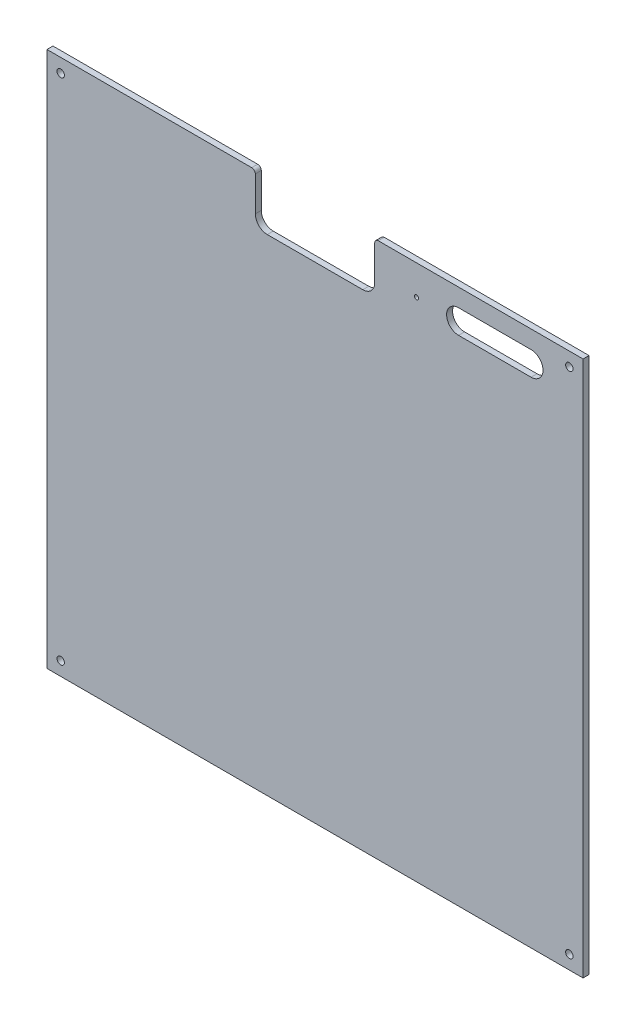
from build123d import *

# Parameters (mm, degrees)
SCHIZZO1_R                   = 3.1
SCHIZZO1_R_2                 = 1.75
ESTRUSIONE_ESTRUSIONE1_DEPTH = 5


with BuildPart() as part:
    # Schizzo1 → Estrusione-Estrusione1 (new body)
    with BuildSketch(Plane.XY):
        with BuildLine():
            Line((0, 0), (0, 449))
            Line((0, 449), (171.5, 449))
            ThreePointArc((171.5, 449), (173.621320344, 448.121320344), (174.5, 446))
            Line((174.5, 446), (174.5, 417))
            ThreePointArc((174.5, 417), (177.428932188, 409.928932188), (184.5, 407))
            Line((184.5, 407), (264.5, 407))
            ThreePointArc((264.5, 407), (271.571067812, 409.928932188), (274.5, 417))
            Line((274.5, 417), (274.5, 446))
            ThreePointArc((274.5, 446), (275.378679656, 448.121320344), (277.5, 449))
            Line((277.5, 449), (449, 449))
            Line((449, 449), (449, 0))
            Line((449, 0), (0, 0))
        make_face()
        with Locations((11.5, 11.5)):
            Circle(SCHIZZO1_R, mode=Mode.SUBTRACT)
        with Locations((437.5, 11.5)):
            Circle(SCHIZZO1_R, mode=Mode.SUBTRACT)
        with Locations((437.5, 437.5)):
            Circle(SCHIZZO1_R, mode=Mode.SUBTRACT)
        with Locations((11.5, 437.5)):
            Circle(SCHIZZO1_R, mode=Mode.SUBTRACT)
        with Locations((309.5, 424)):
            Circle(SCHIZZO1_R_2, mode=Mode.SUBTRACT)
        with BuildLine():
            Line((344.715899345, 434), (405.440355678, 434))
            ThreePointArc((405.440355678, 434), (415.440355678, 424), (405.440355678, 414))
            Line((405.440355678, 414), (344.715899345, 414))
            ThreePointArc((344.715899345, 414), (334.715899345, 424), (344.715899345, 434))
        make_face(mode=Mode.SUBTRACT)
    extrude(amount=ESTRUSIONE_ESTRUSIONE1_DEPTH)


solid = part.part
